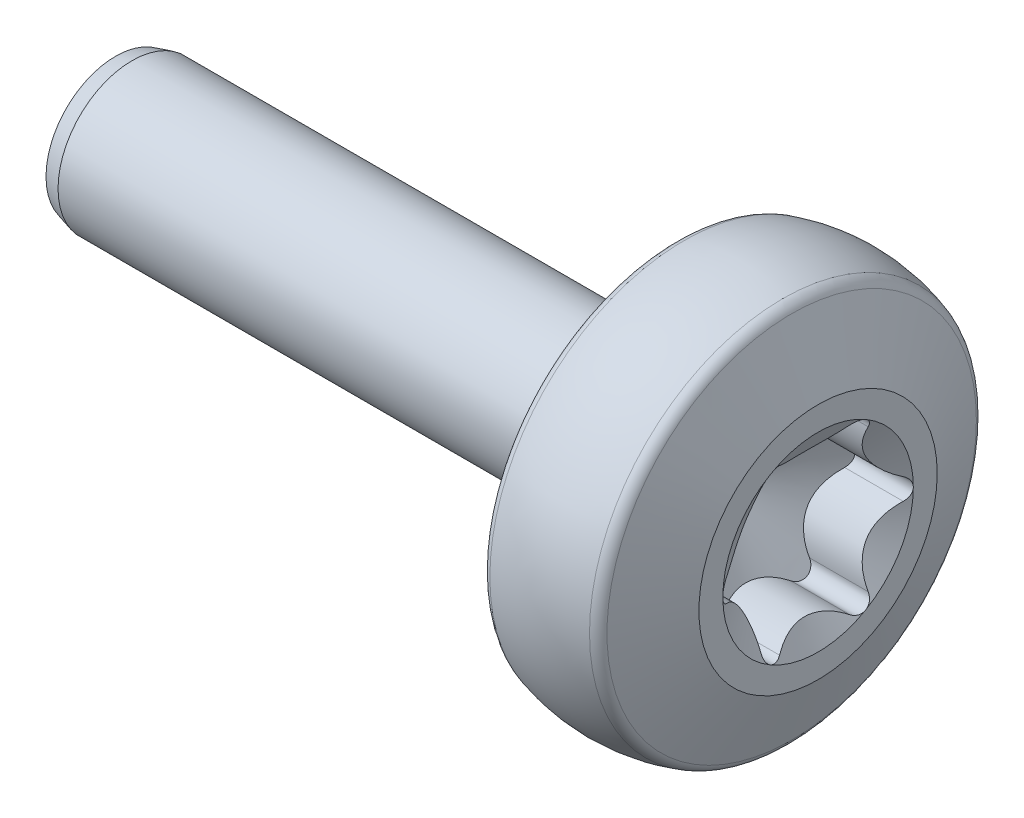
from build123d import *

# Parameters (mm, degrees)
BOSS_EXTRUDE1_REACH = 14.932
SKETCH3_R           = 2.0335875
FILLET1_R           = 0.24638
CHAMFER1_SIZE       = 0.280736842
CHAMFER1_SIZE2      = 0.07522321


with BuildPart() as part:
    # Sketch2 → Revolve1 (revolve)
    with BuildSketch(Plane.XY):
        with BuildLine():
            Line((-5.9944, 0), (5.9944, 0))
            Line((5.9944, 0), (5.9944, 2.0335875))
            Line((5.9944, 2.0335875), (5.50164, 3.25755))
            ThreePointArc((5.50164, 3.25755), (4.51612, 3.429), (3.5306, 3.25755))
            Line((3.5306, 3.25755), (3.5306, 2.003369298))
            ThreePointArc((3.5306, 2.003369298), (3.519440768, 1.97642853), (3.4925, 1.965269298))
            ThreePointArc((3.4925, 1.965269298), (3.465559232, 1.954110067), (3.4544, 1.927169298))
            Line((3.4544, 1.927169298), (3.4544, 1.261978947))
            Line((3.4544, 1.261978947), (-5.9944, 1.261978947))
            Line((-5.9944, 1.261978947), (-5.9944, 0))
        make_face()
    revolve(axis=Axis((-5.9944, 0, 0), (-1, 0, 0)))

    # Sketch12 → Cut-Revolve3 (revolve, cut)
    with BuildSketch(Plane.XY):
        Polygon((5.9944, 1.6256), (4.99348125, 1.6256), (4.054940652, 0), (5.9944, 0), align=None)
    revolve(axis=Axis((-5.9944, 0, 0), (1, 0, 0)), mode=Mode.SUBTRACT)

    # Boss-Extrude1: up to this cone (the profile starts inside it)
    boss_extrude1_end = Plane(origin=(5.9944, 0, 0), z_dir=(1, 0, 0)).offset(-1.939458348) * Cone(1.732e-06, 35.906628234, 20.730700477, align=(Align.CENTER, Align.CENTER, Align.MIN), mode=Mode.PRIVATE)
    # Sketch3 → Boss-Extrude1 (add, up to the surface)
    with BuildSketch(Plane(origin=(5.9944, 0, 0), x_dir=(0, 0, -1), z_dir=(1, 0, 0)), mode=Mode.PRIVATE) as boss_extrude1_sk1:
        Circle(SKETCH3_R)
        with BuildLine():
            ThreePointArc((1.51222877, -0.182266377), (1.594944844, -0.107324354), (1.6256, 0))
            ThreePointArc((1.6256, 0), (1.594944844, 0.107324354), (1.51222877, 0.182266377))
            ThreePointArc((1.51222877, 0.182266377), (1.055858172, 0.6096), (0.913961698, 1.218495343))
            ThreePointArc((0.913961698, 1.218495343), (0.890418039, 1.327600575), (0.8128, 1.407810896))
            ThreePointArc((0.8128, 1.407810896), (0.704526805, 1.434924929), (0.598267073, 1.40076172))
            ThreePointArc((0.598267073, 1.40076172), (0, 1.2192), (-0.598267073, 1.40076172))
            ThreePointArc((-0.598267073, 1.40076172), (-0.704526805, 1.434924929), (-0.8128, 1.407810896))
            ThreePointArc((-0.8128, 1.407810896), (-0.890418039, 1.327600575), (-0.913961698, 1.218495343))
            ThreePointArc((-0.913961698, 1.218495343), (-1.055858172, 0.6096), (-1.51222877, 0.182266377))
            ThreePointArc((-1.51222877, 0.182266377), (-1.594944844, 0.107324354), (-1.6256, 0))
            ThreePointArc((-1.6256, 0), (-1.594944844, -0.107324354), (-1.51222877, -0.182266377))
            ThreePointArc((-1.51222877, -0.182266377), (-1.055858172, -0.6096), (-0.913961698, -1.218495343))
            ThreePointArc((-0.913961698, -1.218495343), (-0.890418039, -1.327600575), (-0.8128, -1.407810896))
            ThreePointArc((-0.8128, -1.407810896), (-0.704526805, -1.434924929), (-0.598267073, -1.40076172))
            ThreePointArc((-0.598267073, -1.40076172), (0, -1.2192), (0.598267073, -1.40076172))
            ThreePointArc((0.598267073, -1.40076172), (0.704526805, -1.434924929), (0.8128, -1.407810896))
            ThreePointArc((0.8128, -1.407810896), (0.890418039, -1.327600575), (0.913961698, -1.218495343))
            ThreePointArc((0.913961698, -1.218495343), (1.055858172, -0.6096), (1.51222877, -0.182266377))
        make_face(mode=Mode.SUBTRACT)
    boss_extrude1_tool1 = extrude(boss_extrude1_sk1.sketch, amount=-BOSS_EXTRUDE1_REACH, mode=Mode.PRIVATE) & boss_extrude1_end
    add(boss_extrude1_tool1.solids().sort_by_distance((5.9944, 0, 1.976069))[0])

    # Cut-Extrude2 cone 1 section (through the dimple's axis) → Cut-Extrude2 (revolve, cut)
    with BuildSketch(Plane(origin=(5.9944, 0, 0), x_dir=(0, 0, -1), z_dir=(0, 1, 0))):
        Polygon((0, 0), (1.6256, 0), (0, 0.938540598), align=None)
    revolve(axis=Axis((5.9944, 0, 0), (-1, 0, 0)), mode=Mode.SUBTRACT)

    # Fillet1
    fillet1_edges = [part.edges().sort_by_distance(p)[0] for p in [
        (3.5306, -3.25755, 0),
        (5.50164, -3.25755, 0),
    ]]
    fillet(fillet1_edges, radius=FILLET1_R)

    # Chamfer1
    chamfer1_edges = [part.edges().sort_by_distance(p)[0] for p in [
        (-5.9944, -1.261978947, 0),
    ]]
    chamfer1_side = [part.faces().sort_by_distance(p)[0] for p in [
        (-1.27, -1.261978947, 0),
    ]]
    chamfer(chamfer1_edges, length=CHAMFER1_SIZE, length2=CHAMFER1_SIZE2, reference=chamfer1_side[0])


solid = part.part
